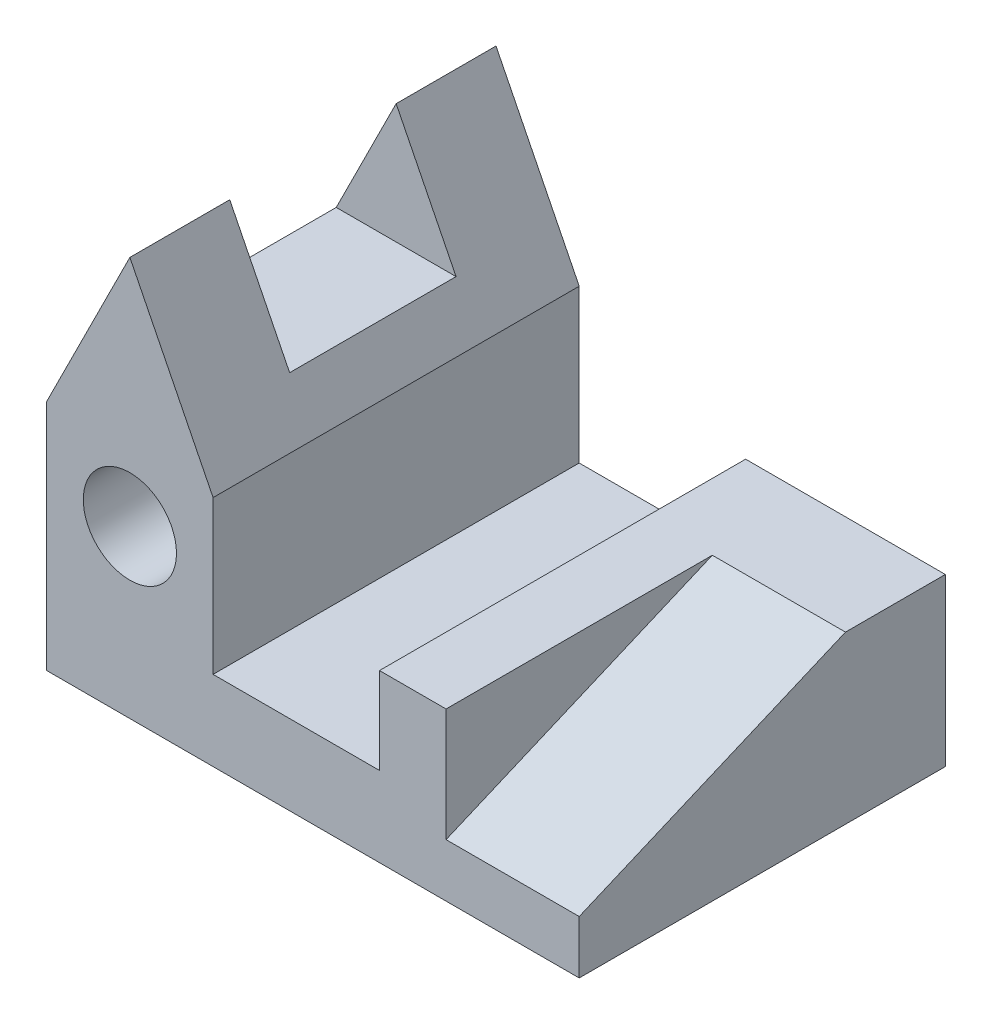
from build123d import *

# Parameters (mm, degrees)
BOSS_EXTRUDE2_DEPTH = 55
SKETCH8_R           = 7
CUT_EXTRUDE2_DEPTH  = 56
CUT_EXTRUDE3_DEPTH  = 25
CUT_EXTRUDE4_DEPTH  = 20


with BuildPart() as part:
    # Sketch7 → Boss-Extrude2 (new body)
    with BuildSketch(Plane.XY):
        Polygon((0, 0), (80, 0), (80, 25), (50, 25), (50, 12), (25, 12), (25, 35), (12.5, 60), (0, 35), align=None)
    extrude(amount=BOSS_EXTRUDE2_DEPTH)

    # Sketch8 → Cut-Extrude2 (cut, through all)
    with BuildSketch(Plane.XY.offset(55)):
        with Locations((12.5, 25)):
            Circle(SKETCH8_R)
    extrude(amount=-CUT_EXTRUDE2_DEPTH, mode=Mode.SUBTRACT)

    # Sketch10 → Cut-Extrude3 (cut)
    with BuildSketch(Plane.XY.offset(40)):
        Polygon((3.5, 42), (21.5, 42), (12.5, 60), align=None)
    extrude(amount=-CUT_EXTRUDE3_DEPTH, mode=Mode.SUBTRACT)

    # Sketch11 → Cut-Extrude4 (cut)
    with BuildSketch(Plane(origin=(80, 0, 0), x_dir=(0, 0, -1), z_dir=(1, 0, 0))):
        Polygon((-55, 8), (-15, 25), (-55, 25), align=None)
    extrude(amount=-CUT_EXTRUDE4_DEPTH, mode=Mode.SUBTRACT)


solid = part.part
